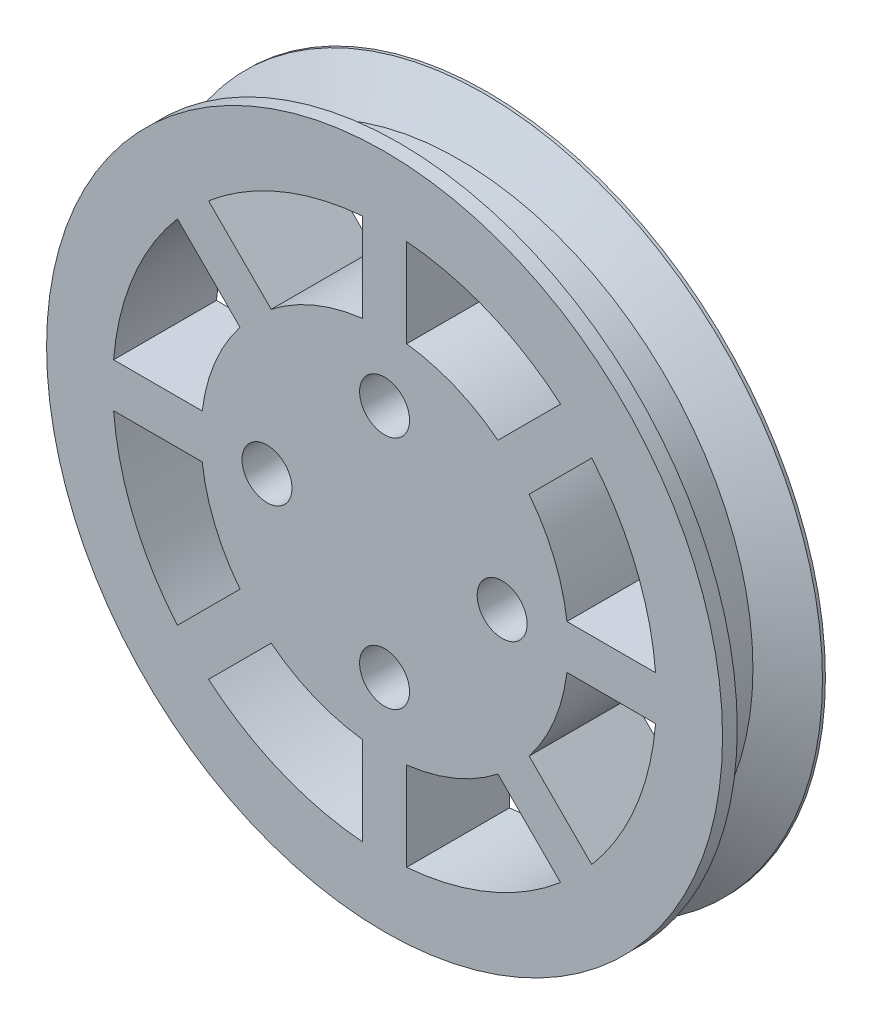
from build123d import *

# Parameters (mm, degrees)
SKETCH1_R                                       = 20
BOSS_EXTRUDE1_DEPTH                             = 3.5
SKETCH4_R                                       = 23
BOSS_EXTRUDE2_DEPTH                             = 1
FILLET1_R                                       = 1
CSK_FOR_M3_FLAT_HEAD_MACHINE_SCREW1_D           = 3.4
CSK_FOR_M3_FLAT_HEAD_MACHINE_SCREW1_DEPTH       = 7
CSK_FOR_M3_FLAT_HEAD_MACHINE_SCREW1_CSINK_D     = 6.3
CSK_FOR_M3_FLAT_HEAD_MACHINE_SCREW1_CSINK_ANGLE = 90
CSK_FOR_M3_FLAT_HEAD_MACHINE_SCREW1_TIP         = 1.021463052
CUT_EXTRUDE1_DEPTH                              = 8


with BuildPart() as part:
    # Sketch1 → Boss-Extrude1 (new body, symmetric)
    with BuildSketch(Plane.XY):
        Circle(SKETCH1_R)
    extrude(amount=BOSS_EXTRUDE1_DEPTH, both=True)

    # Sketch3 → Revolve1 (revolve)
    with BuildSketch(Plane(origin=(0, 0, 0), x_dir=(1, 0, 0), z_dir=(0, 1, 0))):
        Polygon((-20, 3.5), (-23, 3.5), (-23, 3.3), (-20, 1.567949192), align=None)
    revolve(axis=Axis((0, 0, -3.5), (0, 0, 1)))

    # Sketch4 → Boss-Extrude2 (add)
    with BuildSketch(Plane.XY.offset(3.5)):
        Circle(SKETCH4_R)
    extrude(amount=-BOSS_EXTRUDE2_DEPTH)

    # Fillet1
    fillet1_edges = [part.edges().sort_by_distance(p)[0] for p in [
        (-20, 0, 2.5),
    ]]
    fillet(fillet1_edges, radius=FILLET1_R)

    # CSK for M3 Flat Head Machine Screw1
    with Locations(Plane(origin=(0, 0, -3.5), x_dir=(-1, 0, 0), z_dir=(0, 0, -1))):
        with Locations((0, 8), (-8, 0), (0, -8), (8, 0)):
            CounterSinkHole(CSK_FOR_M3_FLAT_HEAD_MACHINE_SCREW1_D / 2, CSK_FOR_M3_FLAT_HEAD_MACHINE_SCREW1_CSINK_D / 2, depth=CSK_FOR_M3_FLAT_HEAD_MACHINE_SCREW1_DEPTH, counter_sink_angle=CSK_FOR_M3_FLAT_HEAD_MACHINE_SCREW1_CSINK_ANGLE)
            with Locations((0, 0, -(CSK_FOR_M3_FLAT_HEAD_MACHINE_SCREW1_DEPTH + CSK_FOR_M3_FLAT_HEAD_MACHINE_SCREW1_TIP / 2))):  # 118° drill point
                Cone(0, CSK_FOR_M3_FLAT_HEAD_MACHINE_SCREW1_D / 2, CSK_FOR_M3_FLAT_HEAD_MACHINE_SCREW1_TIP, mode=Mode.SUBTRACT)

    # Sketch8 → Cut-Extrude1 (cut, through all)
    with BuildSketch(Plane(origin=(0, 0, -3.5), x_dir=(-1, 0, 0), z_dir=(0, 0, -1))):
        with BuildLine():
            Line((-1.5, 18.439088915), (-1.5, 12.409673646))
            ThreePointArc((-1.5, 12.409673646), (-4.783542905, 11.548494156), (-7.714304216, 9.835624559))
            Line((-7.714304216, 9.835624559), (-11.977744639, 14.099064982))
            ThreePointArc((-11.977744639, 14.099064982), (-7.079643499, 17.091771351), (-1.5, 18.439088915))
        make_face()
        with BuildLine():
            Line((1.5, 18.439088915), (1.5, 12.409673646))
            ThreePointArc((1.5, 12.409673646), (4.783542905, 11.548494156), (7.714304216, 9.835624559))
            Line((7.714304216, 9.835624559), (11.977744639, 14.099064982))
            ThreePointArc((11.977744639, 14.099064982), (7.079643499, 17.091771351), (1.5, 18.439088915))
        make_face()
        with BuildLine():
            Line((14.099064982, 11.977744639), (9.835624559, 7.714304216))
            ThreePointArc((9.835624559, 7.714304216), (11.548494156, 4.783542905), (12.409673646, 1.5))
            Line((12.409673646, 1.5), (18.439088915, 1.5))
            ThreePointArc((18.439088915, 1.5), (17.091771351, 7.079643499), (14.099064982, 11.977744639))
        make_face()
        with BuildLine():
            Line((18.439088915, -1.5), (12.409673646, -1.5))
            ThreePointArc((12.409673646, -1.5), (11.548494156, -4.783542905), (9.835624559, -7.714304216))
            Line((9.835624559, -7.714304216), (14.099064982, -11.977744639))
            ThreePointArc((14.099064982, -11.977744639), (17.091771351, -7.079643499), (18.439088915, -1.5))
        make_face()
        with BuildLine():
            Line((11.977744639, -14.099064982), (7.714304216, -9.835624559))
            ThreePointArc((7.714304216, -9.835624559), (4.783542905, -11.548494156), (1.5, -12.409673646))
            Line((1.5, -12.409673646), (1.5, -18.439088915))
            ThreePointArc((1.5, -18.439088915), (7.079643499, -17.091771351), (11.977744639, -14.099064982))
        make_face()
        with BuildLine():
            Line((-1.5, -18.439088915), (-1.5, -12.409673646))
            ThreePointArc((-1.5, -12.409673646), (-4.783542905, -11.548494156), (-7.714304216, -9.835624559))
            Line((-7.714304216, -9.835624559), (-11.977744639, -14.099064982))
            ThreePointArc((-11.977744639, -14.099064982), (-7.079643499, -17.091771351), (-1.5, -18.439088915))
        make_face()
        with BuildLine():
            Line((-14.099064982, -11.977744639), (-9.835624559, -7.714304216))
            ThreePointArc((-9.835624559, -7.714304216), (-11.548494156, -4.783542905), (-12.409673646, -1.5))
            Line((-12.409673646, -1.5), (-18.439088915, -1.5))
            ThreePointArc((-18.439088915, -1.5), (-17.091771351, -7.079643499), (-14.099064982, -11.977744639))
        make_face()
        with BuildLine():
            Line((-18.439088915, 1.5), (-12.409673646, 1.5))
            ThreePointArc((-12.409673646, 1.5), (-11.548494156, 4.783542905), (-9.835624559, 7.714304216))
            Line((-9.835624559, 7.714304216), (-14.099064982, 11.977744639))
            ThreePointArc((-14.099064982, 11.977744639), (-17.091771351, 7.079643499), (-18.439088915, 1.5))
        make_face()
    extrude(amount=-CUT_EXTRUDE1_DEPTH, mode=Mode.SUBTRACT)


solid = part.part
